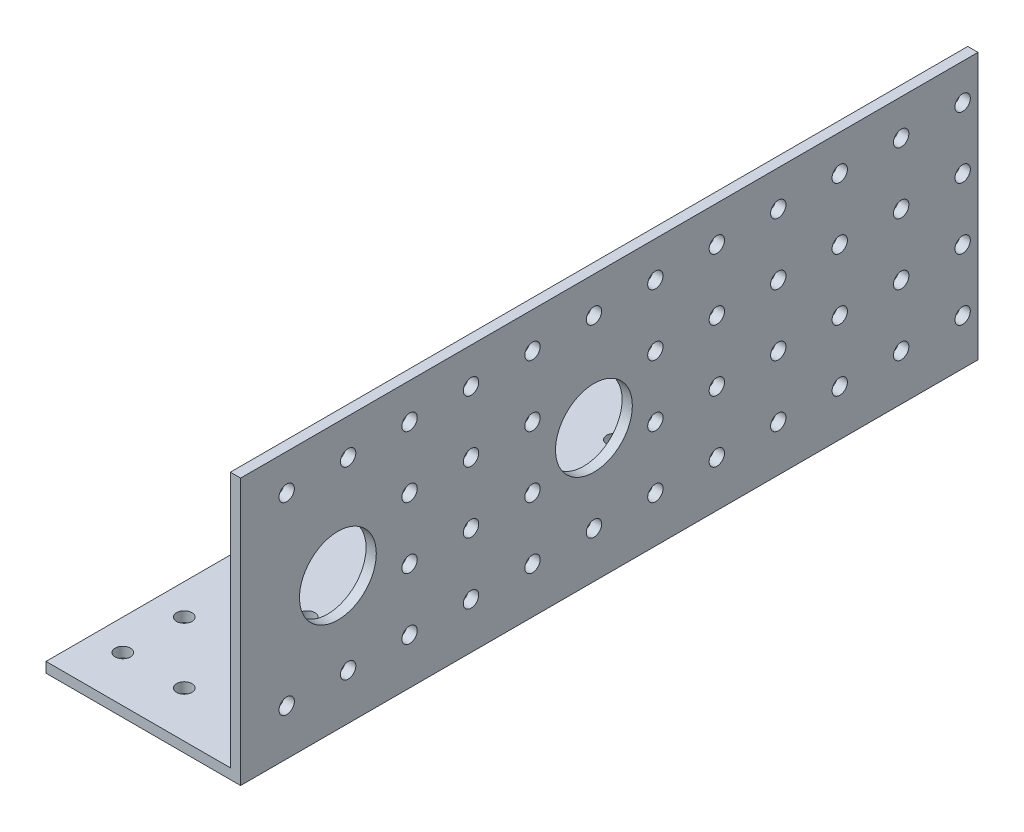
from build123d import *

# Parameters (mm, degrees)
SKETCH1_W           = 38
SKETCH1_H           = 150
SKETCH1_R           = 1.5
BOSS_EXTRUDE1_DEPTH = 2
SKETCH2_W           = 2
SKETCH2_H           = 150
BOSS_EXTRUDE2_DEPTH = 50
SKETCH3_R           = 1.5
SKETCH3_R_2         = 7.5
CUT_EXTRUDE1_DEPTH  = 50
CUT_EXTRUDE2_DEPTH  = 6


with BuildPart() as part:
    # Sketch1 → Boss-Extrude1 (new body)
    with BuildSketch(Plane(origin=(0, 0, 0), x_dir=(1, 0, 0), z_dir=(0, 1, 0))):
        with Locations((19, -75)):
            Rectangle(SKETCH1_W, SKETCH1_H)
        with Locations((6, -3)):
            Circle(SKETCH1_R, mode=Mode.SUBTRACT)
        with Locations((18, -3)):
            Circle(SKETCH1_R, mode=Mode.SUBTRACT)
        with Locations((30, -3)):
            Circle(SKETCH1_R, mode=Mode.SUBTRACT)
        with Locations((18, -15)):
            Circle(SKETCH1_R, mode=Mode.SUBTRACT)
        with Locations((30, -15)):
            Circle(SKETCH1_R, mode=Mode.SUBTRACT)
        with Locations((18, -27)):
            Circle(SKETCH1_R, mode=Mode.SUBTRACT)
        with Locations((30, -27)):
            Circle(SKETCH1_R, mode=Mode.SUBTRACT)
        with Locations((18, -39)):
            Circle(SKETCH1_R, mode=Mode.SUBTRACT)
        with Locations((30, -39)):
            Circle(SKETCH1_R, mode=Mode.SUBTRACT)
        with Locations((18, -51)):
            Circle(SKETCH1_R, mode=Mode.SUBTRACT)
        with Locations((30, -51)):
            Circle(SKETCH1_R, mode=Mode.SUBTRACT)
        with Locations((18, -63)):
            Circle(SKETCH1_R, mode=Mode.SUBTRACT)
        with Locations((30, -63)):
            Circle(SKETCH1_R, mode=Mode.SUBTRACT)
        with Locations((18, -75)):
            Circle(SKETCH1_R, mode=Mode.SUBTRACT)
        with Locations((30, -75)):
            Circle(SKETCH1_R, mode=Mode.SUBTRACT)
        with Locations((18, -87)):
            Circle(SKETCH1_R, mode=Mode.SUBTRACT)
        with Locations((30, -87)):
            Circle(SKETCH1_R, mode=Mode.SUBTRACT)
        with Locations((18, -99)):
            Circle(SKETCH1_R, mode=Mode.SUBTRACT)
        with Locations((30, -99)):
            Circle(SKETCH1_R, mode=Mode.SUBTRACT)
        with Locations((18, -111)):
            Circle(SKETCH1_R, mode=Mode.SUBTRACT)
        with Locations((30, -111)):
            Circle(SKETCH1_R, mode=Mode.SUBTRACT)
        with Locations((18, -123)):
            Circle(SKETCH1_R, mode=Mode.SUBTRACT)
        with Locations((30, -123)):
            Circle(SKETCH1_R, mode=Mode.SUBTRACT)
        with Locations((18, -135)):
            Circle(SKETCH1_R, mode=Mode.SUBTRACT)
        with Locations((30, -135)):
            Circle(SKETCH1_R, mode=Mode.SUBTRACT)
        with Locations((18, -147)):
            Circle(SKETCH1_R, mode=Mode.SUBTRACT)
        with Locations((30, -147)):
            Circle(SKETCH1_R, mode=Mode.SUBTRACT)
        with Locations((6, -15)):
            Circle(SKETCH1_R, mode=Mode.SUBTRACT)
        with Locations((6, -27)):
            Circle(SKETCH1_R, mode=Mode.SUBTRACT)
        with Locations((6, -39)):
            Circle(SKETCH1_R, mode=Mode.SUBTRACT)
        with Locations((6, -51)):
            Circle(SKETCH1_R, mode=Mode.SUBTRACT)
        with Locations((6, -63)):
            Circle(SKETCH1_R, mode=Mode.SUBTRACT)
        with Locations((6, -75)):
            Circle(SKETCH1_R, mode=Mode.SUBTRACT)
        with Locations((6, -87)):
            Circle(SKETCH1_R, mode=Mode.SUBTRACT)
        with Locations((6, -99)):
            Circle(SKETCH1_R, mode=Mode.SUBTRACT)
        with Locations((6, -111)):
            Circle(SKETCH1_R, mode=Mode.SUBTRACT)
        with Locations((6, -123)):
            Circle(SKETCH1_R, mode=Mode.SUBTRACT)
        with Locations((6, -135)):
            Circle(SKETCH1_R, mode=Mode.SUBTRACT)
        with Locations((6, -147)):
            Circle(SKETCH1_R, mode=Mode.SUBTRACT)
    extrude(amount=BOSS_EXTRUDE1_DEPTH)

    # Sketch2 → Boss-Extrude2 (add)
    with BuildSketch(Plane(origin=(0, 2, 0), x_dir=(1, 0, 0), z_dir=(0, 1, 0))):
        with Locations((37, -75)):
            Rectangle(SKETCH2_W, SKETCH2_H)
    extrude(amount=BOSS_EXTRUDE2_DEPTH)

    # Sketch3 → Cut-Extrude1 (cut)
    with BuildSketch(Plane(origin=(38, 0, 0), x_dir=(0, 0, -1), z_dir=(1, 0, 0))):
        with Locations((-147, 45)):
            Circle(SKETCH3_R)
        with Locations((-135, 45)):
            Circle(SKETCH3_R)
        with Locations((-123, 45)):
            Circle(SKETCH3_R)
        with Locations((-111, 45)):
            Circle(SKETCH3_R)
        with Locations((-99, 45)):
            Circle(SKETCH3_R)
        with Locations((-87, 45)):
            Circle(SKETCH3_R)
        with Locations((-75, 45)):
            Circle(SKETCH3_R)
        with Locations((-63, 45)):
            Circle(SKETCH3_R)
        with Locations((-51, 45)):
            Circle(SKETCH3_R)
        with Locations((-39, 45)):
            Circle(SKETCH3_R)
        with Locations((-27, 45)):
            Circle(SKETCH3_R)
        with Locations((-15, 45)):
            Circle(SKETCH3_R)
        with Locations((-3, 45)):
            Circle(SKETCH3_R)
        with Locations((-111, 33)):
            Circle(SKETCH3_R)
        with Locations((-99, 33)):
            Circle(SKETCH3_R)
        with Locations((-87, 33)):
            Circle(SKETCH3_R)
        with Locations((-63, 33)):
            Circle(SKETCH3_R)
        with Locations((-51, 33)):
            Circle(SKETCH3_R)
        with Locations((-39, 33)):
            Circle(SKETCH3_R)
        with Locations((-27, 33)):
            Circle(SKETCH3_R)
        with Locations((-3, 33)):
            Circle(SKETCH3_R)
        with Locations((-111, 21)):
            Circle(SKETCH3_R)
        with Locations((-99, 21)):
            Circle(SKETCH3_R)
        with Locations((-87, 21)):
            Circle(SKETCH3_R)
        with Locations((-63, 21)):
            Circle(SKETCH3_R)
        with Locations((-51, 21)):
            Circle(SKETCH3_R)
        with Locations((-39, 21)):
            Circle(SKETCH3_R)
        with Locations((-27, 21)):
            Circle(SKETCH3_R)
        with Locations((-3, 21)):
            Circle(SKETCH3_R)
        with Locations((-135, 9)):
            Circle(SKETCH3_R)
        with Locations((-123, 9)):
            Circle(SKETCH3_R)
        with Locations((-111, 9)):
            Circle(SKETCH3_R)
        with Locations((-99, 9)):
            Circle(SKETCH3_R)
        with Locations((-87, 9)):
            Circle(SKETCH3_R)
        with Locations((-75, 9)):
            Circle(SKETCH3_R)
        with Locations((-63, 9)):
            Circle(SKETCH3_R)
        with Locations((-51, 9)):
            Circle(SKETCH3_R)
        with Locations((-39, 9)):
            Circle(SKETCH3_R)
        with Locations((-27, 9)):
            Circle(SKETCH3_R)
        with Locations((-15, 9)):
            Circle(SKETCH3_R)
        with Locations((-3, 9)):
            Circle(SKETCH3_R)
        with Locations((-147, 33)):
            Circle(SKETCH3_R)
        with Locations((-147, 21)):
            Circle(SKETCH3_R)
        with Locations((-147, 9)):
            Circle(SKETCH3_R)
        with Locations((-75, 26)):
            Circle(SKETCH3_R_2)
        with Locations((-15, 21)):
            Circle(SKETCH3_R)
        with Locations((-15, 33)):
            Circle(SKETCH3_R)
        with Locations((-125, 26)):
            Circle(SKETCH3_R_2)
    extrude(amount=-CUT_EXTRUDE1_DEPTH, mode=Mode.SUBTRACT)

    # Sketch4 → Cut-Extrude2 (cut)
    with BuildSketch(Plane.XY.offset(150)):
        Polygon((0, 0), (38, 0), (38, 52), (36, 52), (36, 2), (0, 2), align=None)
    extrude(amount=-CUT_EXTRUDE2_DEPTH, mode=Mode.SUBTRACT)


solid = part.part
